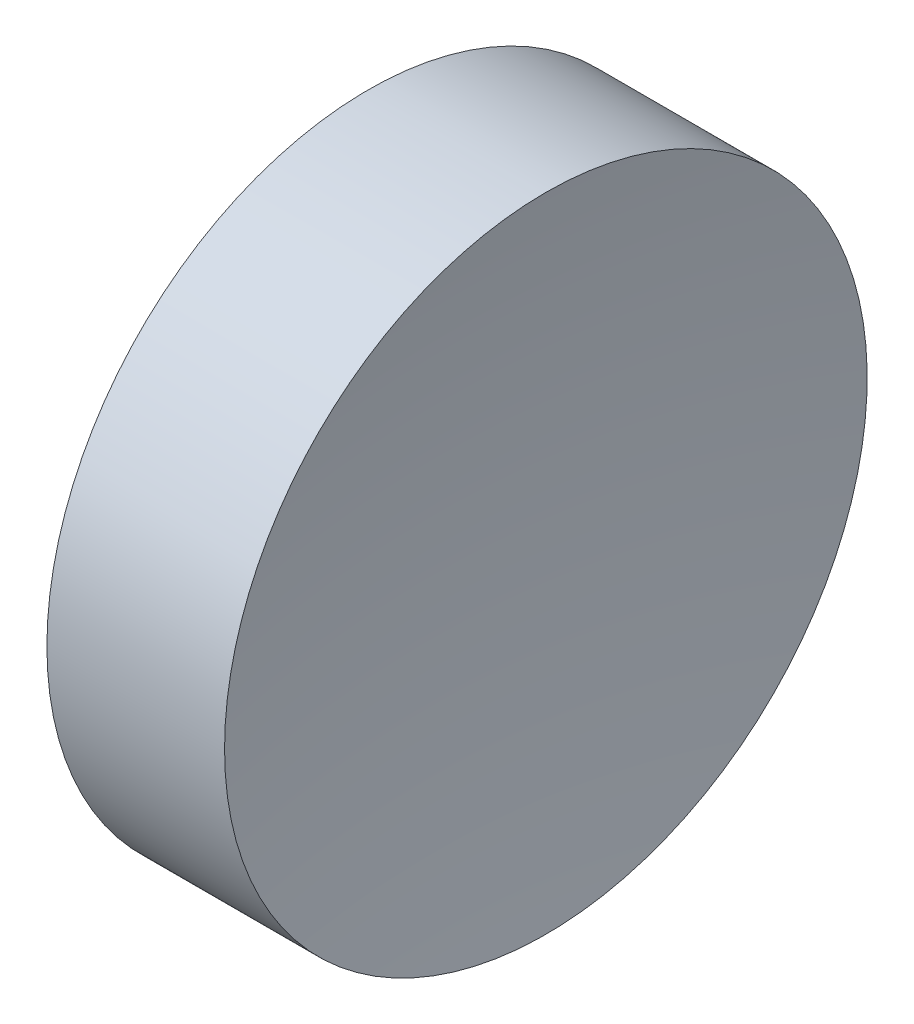
from build123d import *


with BuildPart() as part:
    # 草图1 → 旋转1 (revolve)
    with BuildSketch(Plane.XY):
        with BuildLine():
            Line((22.309268833, 13.031126091), (22.309268833, 16.181126091))
            Line((22.309268833, 16.181126091), (24.050937201, 16.181126091))
            ThreePointArc((24.050937201, 16.181126091), (23.869774567, 14.610754497), (23.809268833, 13.031126091))
            Line((23.809268833, 13.031126091), (22.309268833, 13.031126091))
        make_face()
    revolve(axis=Axis((20.684030635, 13.031126091, 0), (1, 0, 0)))


solid = part.part
